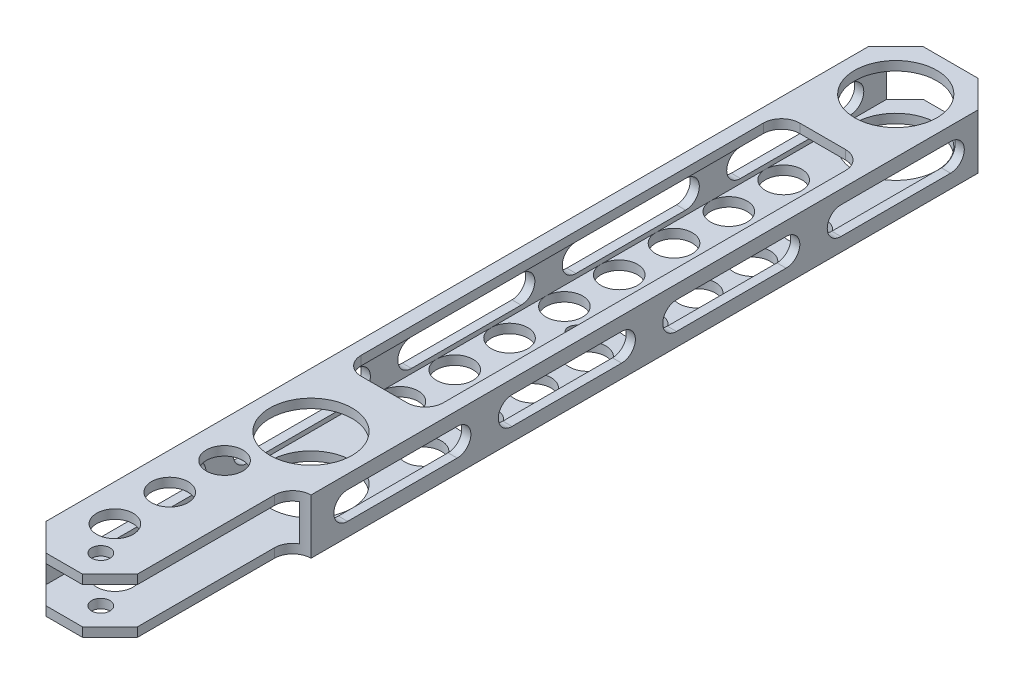
from build123d import *

# Parameters (mm, degrees)
SKETCH1_W           = 38.1
SKETCH1_H           = 19.05
SKETCH1_W_2         = 31.75
SKETCH1_H_2         = 12.7
BOSS_EXTRUDE1_DEPTH = 304.8
SKETCH2_R           = 14.2875
CUT_EXTRUDE1_DEPTH  = 20.05
SKETCH3_R           = 3.175
CUT_EXTRUDE2_DEPTH  = 20.05
CUT_EXTRUDE3_DEPTH  = 20.05
CUT_EXTRUDE6_DEPTH  = 39.1
CUT_EXTRUDE7_REACH  = 21.05
CUT_EXTRUDE8_REACH  = 21.05
SKETCH9_R           = 6.35
CUT_EXTRUDE9_REACH  = 21.05
SKETCH10_R          = 2.667
SKETCH11_R          = 6.35
CUT_EXTRUDE10_DEPTH = 20.05
CUT_EXTRUDE11_DEPTH = 20.05


with BuildPart() as part:
    # Sketch1 → Boss-Extrude1 (new body)
    with BuildSketch(Plane.XY):
        with Locations((19.05, 9.525)):
            Rectangle(SKETCH1_W, SKETCH1_H)
        with Locations((19.05, 9.525)):
            Rectangle(SKETCH1_W_2, SKETCH1_H_2, mode=Mode.SUBTRACT)
    extrude(amount=BOSS_EXTRUDE1_DEPTH)

    # Sketch2 → Cut-Extrude1 (cut, through all)
    with BuildSketch(Plane(origin=(0, 19.05, 0), x_dir=(1, 0, 0), z_dir=(0, 1, 0))):
        with Locations((19.05, -19.05)):
            Circle(SKETCH2_R)
        with Locations((19.05, -222.25)):
            Circle(SKETCH2_R)
    extrude(amount=-CUT_EXTRUDE1_DEPTH, mode=Mode.SUBTRACT)

    # Sketch3 → Cut-Extrude2 (cut, through all)
    with BuildSketch(Plane(origin=(0, 19.05, 0), x_dir=(1, 0, 0), z_dir=(0, 1, 0))):
        with Locations((19.05, -295.275)):
            Circle(SKETCH3_R)
    extrude(amount=-CUT_EXTRUDE2_DEPTH, mode=Mode.SUBTRACT)

    # Sketch4 → Cut-Extrude3 (cut, through all)
    with BuildSketch(Plane(origin=(0, 19.05, 0), x_dir=(1, 0, 0), z_dir=(0, 1, 0))):
        with BuildLine():
            Line((31.75, -304.8), (31.75, -247.65))
            ThreePointArc((31.75, -247.65), (33.609871939, -243.159871939), (38.1, -241.3))
            Line((38.1, -241.3), (38.1, -304.8))
            Line((38.1, -304.8), (31.75, -304.8))
        make_face()
    extrude(amount=-CUT_EXTRUDE3_DEPTH, mode=Mode.SUBTRACT)

    # Sketch7 → Cut-Extrude6 (cut, through all)
    with BuildSketch(Plane.ZY):
        with BuildLine():
            Line((19.05, 14.2875), (57.15, 14.2875))
            ThreePointArc((57.15, 14.2875), (61.9125, 9.525), (57.15, 4.7625))
            Line((57.15, 4.7625), (19.05, 4.7625))
            ThreePointArc((19.05, 4.7625), (14.2875, 9.525), (19.05, 14.2875))
        make_face()
        with BuildLine():
            Line((76.2, 14.2875), (114.3, 14.2875))
            ThreePointArc((114.3, 14.2875), (119.0625, 9.525), (114.3, 4.7625))
            Line((114.3, 4.7625), (76.2, 4.7625))
            ThreePointArc((76.2, 4.7625), (71.4375, 9.525), (76.2, 14.2875))
        make_face()
        with BuildLine():
            Line((133.35, 14.2875), (171.45, 14.2875))
            ThreePointArc((171.45, 14.2875), (176.2125, 9.525), (171.45, 4.7625))
            Line((171.45, 4.7625), (133.35, 4.7625))
            ThreePointArc((133.35, 4.7625), (128.5875, 9.525), (133.35, 14.2875))
        make_face()
        with BuildLine():
            Line((190.5, 14.2875), (228.6, 14.2875))
            ThreePointArc((228.6, 14.2875), (233.3625, 9.525), (228.6, 4.7625))
            Line((228.6, 4.7625), (190.5, 4.7625))
            ThreePointArc((190.5, 4.7625), (185.7375, 9.525), (190.5, 14.2875))
        make_face()
        with BuildLine():
            Line((247.65, 14.2875), (285.75, 14.2875))
            ThreePointArc((285.75, 14.2875), (290.5125, 9.525), (285.75, 4.7625))
            Line((285.75, 4.7625), (247.65, 4.7625))
            ThreePointArc((247.65, 4.7625), (242.8875, 9.525), (247.65, 14.2875))
        make_face()
    extrude(amount=-CUT_EXTRUDE6_DEPTH, mode=Mode.SUBTRACT)

    # Sketch8 → Cut-Extrude7 (cut, up to next)
    with BuildSketch(Plane(origin=(0, 19.05, 0), x_dir=(1, 0, 0), z_dir=(0, 1, 0)), mode=Mode.PRIVATE) as cut_extrude7_sk1:
        with BuildLine():
            Line((11.1125, -44.45), (26.9875, -44.45))
            ThreePointArc((26.9875, -44.45), (31.477628061, -46.309871939), (33.3375, -50.8))
            Line((33.3375, -50.8), (33.3375, -190.5))
            ThreePointArc((33.3375, -190.5), (31.477628061, -194.990128061), (26.9875, -196.85))
            Line((26.9875, -196.85), (11.1125, -196.85))
            ThreePointArc((11.1125, -196.85), (6.622371939, -194.990128061), (4.7625, -190.5))
            Line((4.7625, -190.5), (4.7625, -50.8))
            ThreePointArc((4.7625, -50.8), (6.622371939, -46.309871939), (11.1125, -44.45))
        make_face()
    cut_extrude7_tool1 = extrude(cut_extrude7_sk1.sketch, amount=-CUT_EXTRUDE7_REACH, mode=Mode.PRIVATE) & part.part
    add(cut_extrude7_tool1.solids().sort_by_distance((19.05, 19.05, 120.65))[0], mode=Mode.SUBTRACT)

    # Sketch9 → Cut-Extrude8 (cut, up to next)
    with BuildSketch(Plane.XZ, mode=Mode.PRIVATE) as cut_extrude8_sk1:
        with Locations((9.525, 48.475738686)):
            Circle(SKETCH9_R)
    cut_extrude8_tool1 = extrude(cut_extrude8_sk1.sketch, amount=-CUT_EXTRUDE8_REACH, mode=Mode.PRIVATE) & part.part
    add(cut_extrude8_tool1.solids().sort_by_distance((9.525, 0, 48.475739))[0], mode=Mode.SUBTRACT)
    # Sketch9 → Cut-Extrude8 (cut, up to next)
    with BuildSketch(Plane.XZ, mode=Mode.PRIVATE) as cut_extrude8_sk2:
        with Locations((28.575, 59.474261314)):
            Circle(SKETCH9_R)
    cut_extrude8_tool2 = extrude(cut_extrude8_sk2.sketch, amount=-CUT_EXTRUDE8_REACH, mode=Mode.PRIVATE) & part.part
    add(cut_extrude8_tool2.solids().sort_by_distance((28.575, 0, 59.474261))[0], mode=Mode.SUBTRACT)
    # Sketch9 → Cut-Extrude8 (cut, up to next)
    with BuildSketch(Plane.XZ, mode=Mode.PRIVATE) as cut_extrude8_sk3:
        with Locations((9.525, 67.525738686)):
            Circle(SKETCH9_R)
    cut_extrude8_tool3 = extrude(cut_extrude8_sk3.sketch, amount=-CUT_EXTRUDE8_REACH, mode=Mode.PRIVATE) & part.part
    add(cut_extrude8_tool3.solids().sort_by_distance((9.525, 0, 67.525739))[0], mode=Mode.SUBTRACT)
    # Sketch9 → Cut-Extrude8 (cut, up to next)
    with BuildSketch(Plane.XZ, mode=Mode.PRIVATE) as cut_extrude8_sk4:
        with Locations((28.575, 78.524261314)):
            Circle(SKETCH9_R)
    cut_extrude8_tool4 = extrude(cut_extrude8_sk4.sketch, amount=-CUT_EXTRUDE8_REACH, mode=Mode.PRIVATE) & part.part
    add(cut_extrude8_tool4.solids().sort_by_distance((28.575, 0, 78.524261))[0], mode=Mode.SUBTRACT)
    # Sketch9 → Cut-Extrude8 (cut, up to next)
    with BuildSketch(Plane.XZ, mode=Mode.PRIVATE) as cut_extrude8_sk5:
        with Locations((9.525, 86.575738686)):
            Circle(SKETCH9_R)
    cut_extrude8_tool5 = extrude(cut_extrude8_sk5.sketch, amount=-CUT_EXTRUDE8_REACH, mode=Mode.PRIVATE) & part.part
    add(cut_extrude8_tool5.solids().sort_by_distance((9.525, 0, 86.575739))[0], mode=Mode.SUBTRACT)
    # Sketch9 → Cut-Extrude8 (cut, up to next)
    with BuildSketch(Plane.XZ, mode=Mode.PRIVATE) as cut_extrude8_sk6:
        with Locations((28.575, 97.574261314)):
            Circle(SKETCH9_R)
    cut_extrude8_tool6 = extrude(cut_extrude8_sk6.sketch, amount=-CUT_EXTRUDE8_REACH, mode=Mode.PRIVATE) & part.part
    add(cut_extrude8_tool6.solids().sort_by_distance((28.575, 0, 97.574261))[0], mode=Mode.SUBTRACT)
    # Sketch9 → Cut-Extrude8 (cut, up to next)
    with BuildSketch(Plane.XZ, mode=Mode.PRIVATE) as cut_extrude8_sk7:
        with Locations((9.525, 105.625738686)):
            Circle(SKETCH9_R)
    cut_extrude8_tool7 = extrude(cut_extrude8_sk7.sketch, amount=-CUT_EXTRUDE8_REACH, mode=Mode.PRIVATE) & part.part
    add(cut_extrude8_tool7.solids().sort_by_distance((9.525, 0, 105.625739))[0], mode=Mode.SUBTRACT)
    # Sketch9 → Cut-Extrude8 (cut, up to next)
    with BuildSketch(Plane.XZ, mode=Mode.PRIVATE) as cut_extrude8_sk8:
        with Locations((28.575, 116.624261314)):
            Circle(SKETCH9_R)
    cut_extrude8_tool8 = extrude(cut_extrude8_sk8.sketch, amount=-CUT_EXTRUDE8_REACH, mode=Mode.PRIVATE) & part.part
    add(cut_extrude8_tool8.solids().sort_by_distance((28.575, 0, 116.624261))[0], mode=Mode.SUBTRACT)
    # Sketch9 → Cut-Extrude8 (cut, up to next)
    with BuildSketch(Plane.XZ, mode=Mode.PRIVATE) as cut_extrude8_sk9:
        with Locations((9.525, 124.675738686)):
            Circle(SKETCH9_R)
    cut_extrude8_tool9 = extrude(cut_extrude8_sk9.sketch, amount=-CUT_EXTRUDE8_REACH, mode=Mode.PRIVATE) & part.part
    add(cut_extrude8_tool9.solids().sort_by_distance((9.525, 0, 124.675739))[0], mode=Mode.SUBTRACT)
    # Sketch9 → Cut-Extrude8 (cut, up to next)
    with BuildSketch(Plane.XZ, mode=Mode.PRIVATE) as cut_extrude8_sk10:
        with Locations((28.575, 135.674261314)):
            Circle(SKETCH9_R)
    cut_extrude8_tool10 = extrude(cut_extrude8_sk10.sketch, amount=-CUT_EXTRUDE8_REACH, mode=Mode.PRIVATE) & part.part
    add(cut_extrude8_tool10.solids().sort_by_distance((28.575, 0, 135.674261))[0], mode=Mode.SUBTRACT)
    # Sketch9 → Cut-Extrude8 (cut, up to next)
    with BuildSketch(Plane.XZ, mode=Mode.PRIVATE) as cut_extrude8_sk11:
        with Locations((9.525, 143.725738686)):
            Circle(SKETCH9_R)
    cut_extrude8_tool11 = extrude(cut_extrude8_sk11.sketch, amount=-CUT_EXTRUDE8_REACH, mode=Mode.PRIVATE) & part.part
    add(cut_extrude8_tool11.solids().sort_by_distance((9.525, 0, 143.725739))[0], mode=Mode.SUBTRACT)
    # Sketch9 → Cut-Extrude8 (cut, up to next)
    with BuildSketch(Plane.XZ, mode=Mode.PRIVATE) as cut_extrude8_sk12:
        with Locations((28.575, 154.724261314)):
            Circle(SKETCH9_R)
    cut_extrude8_tool12 = extrude(cut_extrude8_sk12.sketch, amount=-CUT_EXTRUDE8_REACH, mode=Mode.PRIVATE) & part.part
    add(cut_extrude8_tool12.solids().sort_by_distance((28.575, 0, 154.724261))[0], mode=Mode.SUBTRACT)
    # Sketch9 → Cut-Extrude8 (cut, up to next)
    with BuildSketch(Plane.XZ, mode=Mode.PRIVATE) as cut_extrude8_sk13:
        with Locations((9.525, 162.775738686)):
            Circle(SKETCH9_R)
    cut_extrude8_tool13 = extrude(cut_extrude8_sk13.sketch, amount=-CUT_EXTRUDE8_REACH, mode=Mode.PRIVATE) & part.part
    add(cut_extrude8_tool13.solids().sort_by_distance((9.525, 0, 162.775739))[0], mode=Mode.SUBTRACT)
    # Sketch9 → Cut-Extrude8 (cut, up to next)
    with BuildSketch(Plane.XZ, mode=Mode.PRIVATE) as cut_extrude8_sk14:
        with Locations((28.575, 173.774261314)):
            Circle(SKETCH9_R)
    cut_extrude8_tool14 = extrude(cut_extrude8_sk14.sketch, amount=-CUT_EXTRUDE8_REACH, mode=Mode.PRIVATE) & part.part
    add(cut_extrude8_tool14.solids().sort_by_distance((28.575, 0, 173.774261))[0], mode=Mode.SUBTRACT)
    # Sketch9 → Cut-Extrude8 (cut, up to next)
    with BuildSketch(Plane.XZ, mode=Mode.PRIVATE) as cut_extrude8_sk15:
        with Locations((9.525, 181.825738686)):
            Circle(SKETCH9_R)
    cut_extrude8_tool15 = extrude(cut_extrude8_sk15.sketch, amount=-CUT_EXTRUDE8_REACH, mode=Mode.PRIVATE) & part.part
    add(cut_extrude8_tool15.solids().sort_by_distance((9.525, 0, 181.825739))[0], mode=Mode.SUBTRACT)
    # Sketch9 → Cut-Extrude8 (cut, up to next)
    with BuildSketch(Plane.XZ, mode=Mode.PRIVATE) as cut_extrude8_sk16:
        with Locations((28.575, 192.824261314)):
            Circle(SKETCH9_R)
    cut_extrude8_tool16 = extrude(cut_extrude8_sk16.sketch, amount=-CUT_EXTRUDE8_REACH, mode=Mode.PRIVATE) & part.part
    add(cut_extrude8_tool16.solids().sort_by_distance((28.575, 0, 192.824261))[0], mode=Mode.SUBTRACT)

    # Sketch10 → Cut-Extrude9 (cut, up to next)
    with BuildSketch(Plane.XZ, mode=Mode.PRIVATE) as cut_extrude9_sk1:
        with Locations((19.05, 130.175)):
            Circle(SKETCH10_R)
    cut_extrude9_tool1 = extrude(cut_extrude9_sk1.sketch, amount=-CUT_EXTRUDE9_REACH, mode=Mode.PRIVATE) & part.part
    add(cut_extrude9_tool1.solids().sort_by_distance((19.05, 0, 130.175))[0], mode=Mode.SUBTRACT)

    # Sketch11 → Cut-Extrude10 (cut, through all)
    with BuildSketch(Plane(origin=(0, 19.05, 0), x_dir=(1, 0, 0), z_dir=(0, 1, 0))):
        with Locations((12.7, -245.927225036)):
            Circle(SKETCH11_R)
        with Locations((12.7, -264.977225036)):
            Circle(SKETCH11_R)
        with Locations((12.7, -284.027225036)):
            Circle(SKETCH11_R)
    extrude(amount=-CUT_EXTRUDE10_DEPTH, mode=Mode.SUBTRACT)

    # Sketch12 → Cut-Extrude11 (cut, through all)
    with BuildSketch(Plane(origin=(0, 19.05, 0), x_dir=(1, 0, 0), z_dir=(0, 1, 0))):
        Polygon((28.575, 0), (38.1, -9.525), (38.1, 0), align=None)
        Polygon((0, 0), (9.525, 0), (0, -9.525), align=None)
        Polygon((9.525, -304.8), (0, -295.275), (0, -304.8), align=None)
        Polygon((31.75, -304.8), (22.225, -304.8), (31.75, -295.275), align=None)
    extrude(amount=-CUT_EXTRUDE11_DEPTH, mode=Mode.SUBTRACT)


solid = part.part
